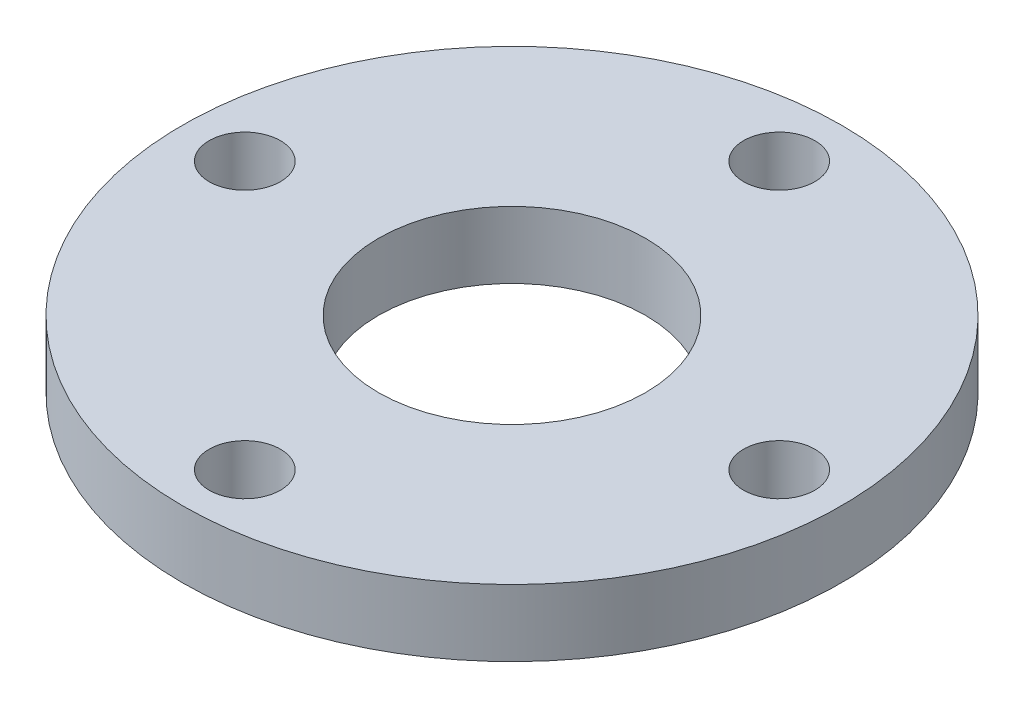
from build123d import *

# Parameters (mm, degrees)
SKETCH_1_R      = 14.8
SKETCH_1_R_2    = 6
SKETCH_1_R_3    = 1.6
EXTRUDE_1_DEPTH = 3


with BuildPart() as part:
    # 草图1 → 凸台-拉伸1 (new body)
    with BuildSketch(Plane(origin=(0, 0, 0), x_dir=(1, 0, 0), z_dir=(0, 1, 0))):
        Circle(SKETCH_1_R)
        Circle(SKETCH_1_R_2, mode=Mode.SUBTRACT)
        with Locations((12, 0)):
            Circle(SKETCH_1_R_3, mode=Mode.SUBTRACT)
        with Locations((0, -12)):
            Circle(SKETCH_1_R_3, mode=Mode.SUBTRACT)
        with Locations((-12, 0)):
            Circle(SKETCH_1_R_3, mode=Mode.SUBTRACT)
        with Locations((0, 12)):
            Circle(SKETCH_1_R_3, mode=Mode.SUBTRACT)
    extrude(amount=EXTRUDE_1_DEPTH)


solid = part.part
